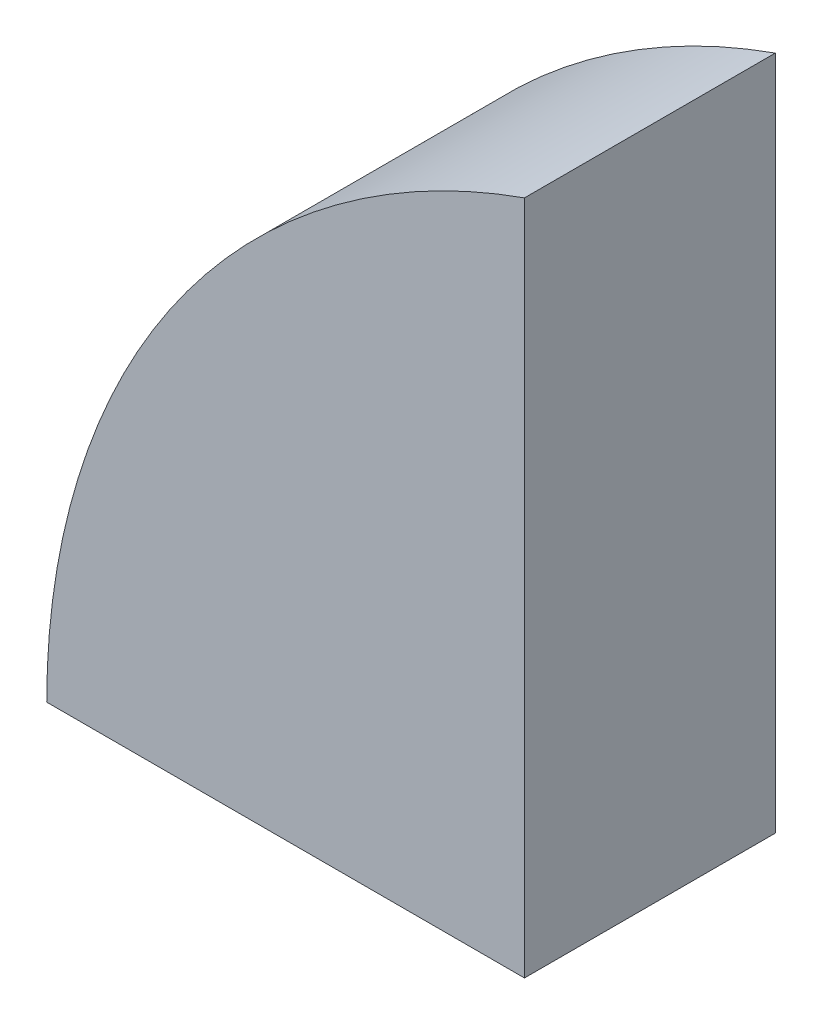
from build123d import *

# Parameters (mm, degrees)
BOSS_EXTRU_2_DEPTH = 70


with BuildPart() as part:
    # Esquisse2 → Boss.-Extru.2 (new body)
    with BuildSketch(Plane.XY):
        with BuildLine():
            Line((-124.883008839, -169.122807018), (8.450324494, -169.122807018))
            Line((8.450324494, -169.122807018), (8.450324494, 19.439001299))
            ThreePointArc((8.450324494, 19.439001299), (-88.182325025, -53.65275318), (-124.883008839, -169.122807018))
        make_face()
    extrude(amount=BOSS_EXTRU_2_DEPTH)


solid = part.part
